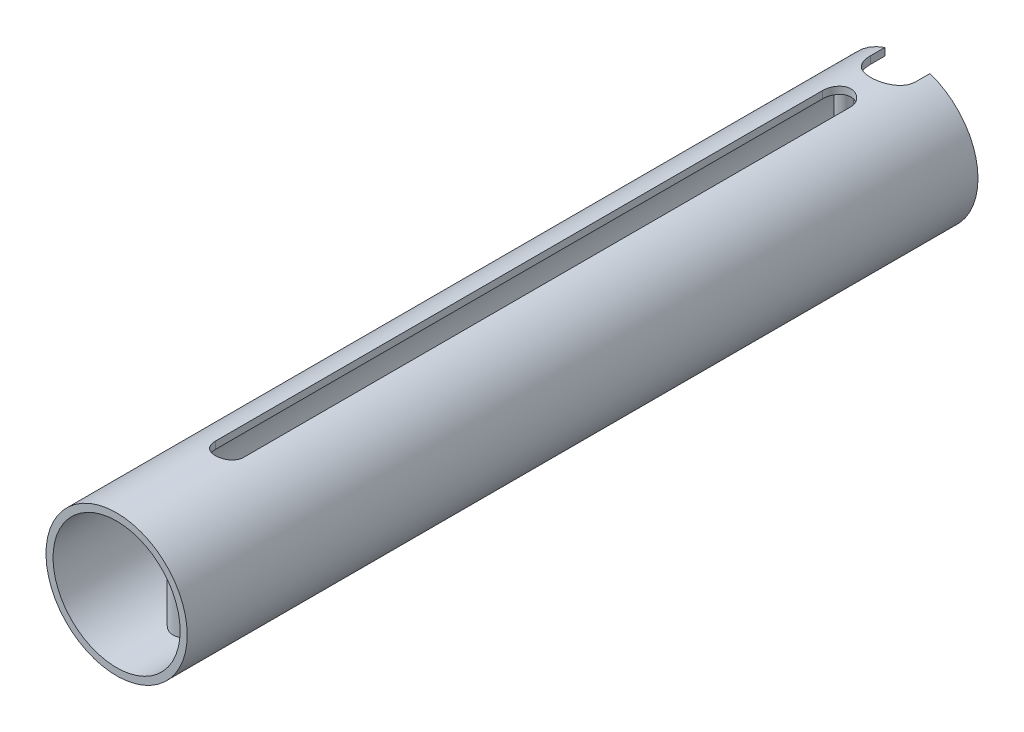
from build123d import *

# Parameters (mm, degrees)
ESQUISSE1_R                    = 5
ESQUISSE1_R_2                  = 4.5
BOSS_EXTRU_1_DEPTH             = 28
BOSS_EXTRU_2_REACH             = 7
ESQUISSE2_R                    = 1
ESQUISSE2_R_2                  = 0.5
BOSS_EXTRU_2_DIRECTION_2_REACH = 7
ENL_V_MAT_EXTRU_1_DEPTH        = 6
ENL_V_MAT_EXTRU_1_DEPTH_BACK   = 6
ENL_V_MAT_EXTRU_2_DEPTH        = 6.000000118
ENL_V_MAT_EXTRU_2_DEPTH_BACK   = 6.000000118


with BuildPart() as part:
    # Esquisse1 → Boss.-Extru.1 (new body, symmetric)
    with BuildSketch(Plane.XY):
        Circle(ESQUISSE1_R)
        Circle(ESQUISSE1_R_2, mode=Mode.SUBTRACT)
    extrude(amount=BOSS_EXTRU_1_DEPTH, both=True)

    # Esquisse2 → Boss.-Extru.2 (add, up to next)
    with BuildSketch(Plane(origin=(0, 0, 0), x_dir=(1, 0, 0), z_dir=(0, 1, 0)), mode=Mode.PRIVATE) as boss_extru_2_sk1:
        with Locations((0, -23)):
            Circle(ESQUISSE2_R)
    boss_extru_2_tool1 = extrude(boss_extru_2_sk1.sketch, amount=BOSS_EXTRU_2_REACH, mode=Mode.PRIVATE) - part.part
    add(boss_extru_2_tool1.solids().sort_by_distance((0, 0, 23))[0])
    # Esquisse2 → Boss.-Extru.2 (add, up to next)
    with BuildSketch(Plane(origin=(0, 0, 0), x_dir=(1, 0, 0), z_dir=(0, 1, 0)), mode=Mode.PRIVATE) as boss_extru_2_sk2:
        with Locations((-3, 26.5)):
            Circle(ESQUISSE2_R_2)
    boss_extru_2_tool2 = extrude(boss_extru_2_sk2.sketch, amount=BOSS_EXTRU_2_REACH, mode=Mode.PRIVATE) - part.part
    add(boss_extru_2_tool2.solids().sort_by_distance((-3, 0, -26.5))[0])

    # Esquisse2 → Boss.-Extru.2 direction 2 (add, up to next)
    with BuildSketch(Plane(origin=(0, 0, 0), x_dir=(1, 0, 0), z_dir=(0, 1, 0)), mode=Mode.PRIVATE) as boss_extru_2_direction_2_sk1:
        with Locations((0, -23)):
            Circle(ESQUISSE2_R)
    boss_extru_2_direction_2_tool1 = extrude(boss_extru_2_direction_2_sk1.sketch, amount=-BOSS_EXTRU_2_DIRECTION_2_REACH, mode=Mode.PRIVATE) - part.part
    add(boss_extru_2_direction_2_tool1.solids().sort_by_distance((0, 0, 23))[0])
    # Esquisse2 → Boss.-Extru.2 direction 2 (add, up to next)
    with BuildSketch(Plane(origin=(0, 0, 0), x_dir=(1, 0, 0), z_dir=(0, 1, 0)), mode=Mode.PRIVATE) as boss_extru_2_direction_2_sk2:
        with Locations((-3, 26.5)):
            Circle(ESQUISSE2_R_2)
    boss_extru_2_direction_2_tool2 = extrude(boss_extru_2_direction_2_sk2.sketch, amount=-BOSS_EXTRU_2_DIRECTION_2_REACH, mode=Mode.PRIVATE) - part.part
    add(boss_extru_2_direction_2_tool2.solids().sort_by_distance((-3, 0, -26.5))[0])

    # Esquisse3 → Enlèv. mat.-Extru.1 (cut, two sides)
    with BuildSketch(Plane(origin=(0, 0, 0), x_dir=(1, 0, 0), z_dir=(0, 1, 0))) as enl_v_mat_extru_1_sk:
        with BuildLine():
            Line((1, 23), (1, -20))
            ThreePointArc((1, -20), (0, -21), (-1, -20))
            Line((-1, -20), (-1, 23))
            ThreePointArc((-1, 23), (0, 24), (1, 23))
        make_face()
    extrude(amount=ENL_V_MAT_EXTRU_1_DEPTH, mode=Mode.SUBTRACT)
    extrude(enl_v_mat_extru_1_sk.sketch, amount=-ENL_V_MAT_EXTRU_1_DEPTH_BACK, mode=Mode.SUBTRACT)

    # Esquisse4 → Enlèv. mat.-Extru.2 (cut, two sides)
    with BuildSketch(Plane(origin=(0, 0, 0), x_dir=(1, 0, 0), z_dir=(0, 1, 0))) as enl_v_mat_extru_2_sk:
        with BuildLine():
            Line((-1.6, 27), (-1.6, 28))
            ThreePointArc((-1.6, 28), (0, 29.6), (1.6, 28))
            Line((1.6, 28), (1.6, 27))
            ThreePointArc((1.6, 27), (0, 25.4), (-1.6, 27))
        make_face()
    extrude(amount=ENL_V_MAT_EXTRU_2_DEPTH, mode=Mode.SUBTRACT)
    extrude(enl_v_mat_extru_2_sk.sketch, amount=-ENL_V_MAT_EXTRU_2_DEPTH_BACK, mode=Mode.SUBTRACT)


solid = part.part
